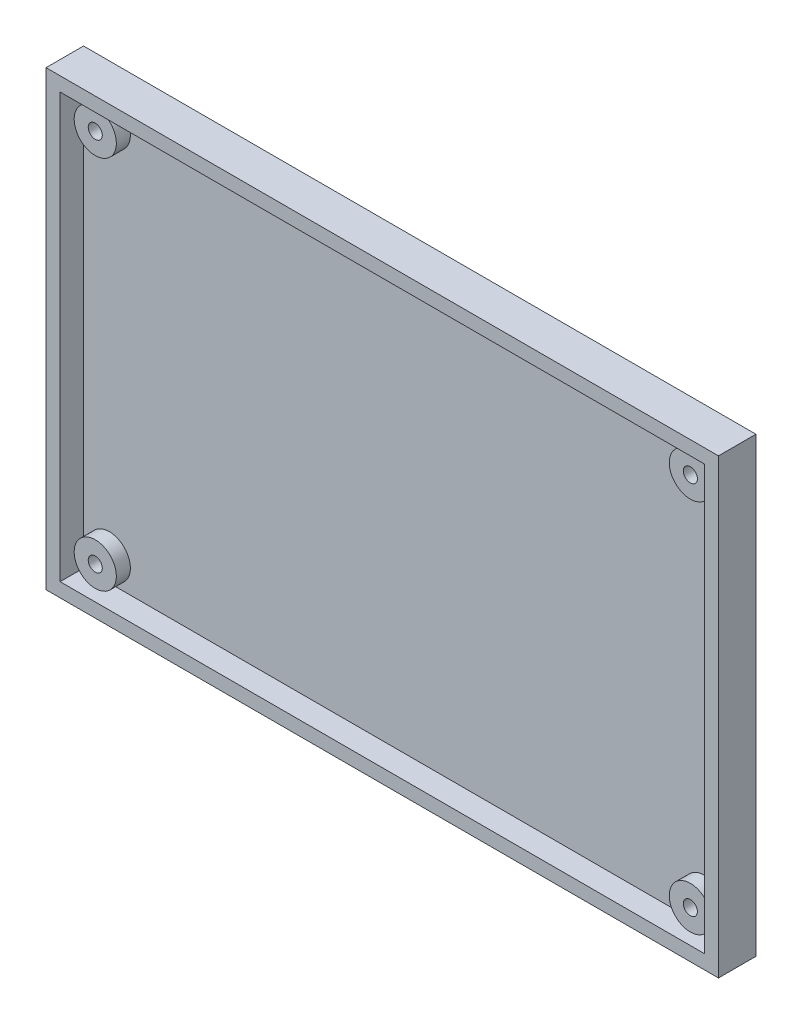
from build123d import *

# Parameters (mm, degrees)
SKETCH1_W           = 143.5
SKETCH1_H           = 96.5
SKETCH1_R           = 1.5
BOSS_EXTRUDE1_DEPTH = 8
SHELL1_T            = -3
SKETCH2_W           = 137.5
SKETCH2_H           = 90.5
CUT_EXTRUDE1_DEPTH  = 2


with BuildPart() as part:
    # Sketch1 → Boss-Extrude1 (new body)
    with BuildSketch(Plane.XY):
        with Locations((71.75, 48.25)):
            Rectangle(SKETCH1_W, SKETCH1_H)
        with Locations((8.5, 88)):
            Circle(SKETCH1_R, mode=Mode.SUBTRACT)
        with Locations((8.5, 8)):
            Circle(SKETCH1_R, mode=Mode.SUBTRACT)
        with Locations((135.5, 8)):
            Circle(SKETCH1_R, mode=Mode.SUBTRACT)
        with Locations((135.5, 88)):
            Circle(SKETCH1_R, mode=Mode.SUBTRACT)
    extrude(amount=BOSS_EXTRUDE1_DEPTH)

    # Shell1
    shell1_openings = [part.faces().sort_by_distance(p)[0] for p in [
        (71.75, 48.25, 8),
    ]]
    offset(amount=SHELL1_T, openings=shell1_openings, kind=Kind.INTERSECTION)

    # Sketch2 → Cut-Extrude1 (cut)
    with BuildSketch(Plane.XY.offset(8)):
        with Locations((71.75, 48.25)):
            Rectangle(SKETCH2_W, SKETCH2_H)
    extrude(amount=-CUT_EXTRUDE1_DEPTH, mode=Mode.SUBTRACT)


solid = part.part
